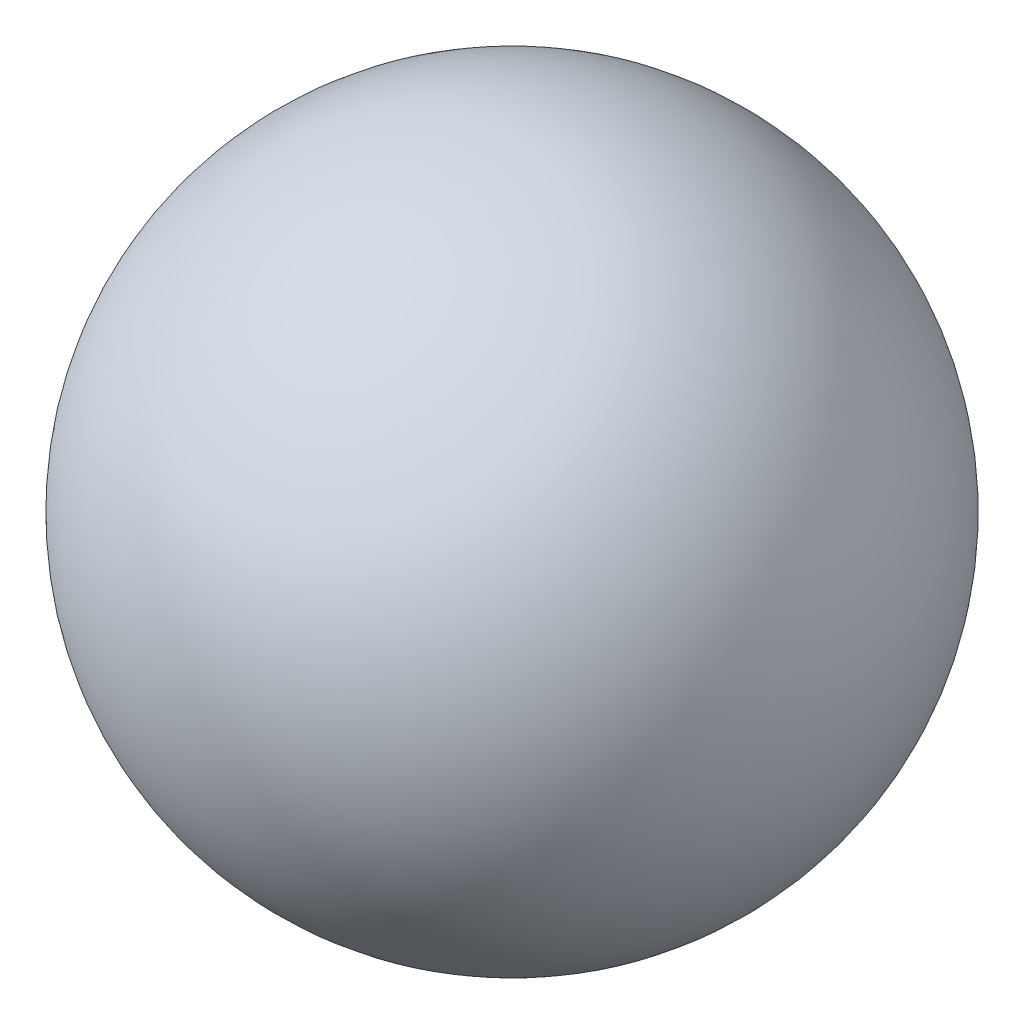
from build123d import *


with BuildPart() as part:
    # Sketch1 → Revolve2 (revolve)
    with BuildSketch(Plane.XY):
        with BuildLine():
            Line((0, 6.35), (0, -6.35))
            ThreePointArc((0, -6.35), (6.35, 0), (0, 6.35))
        make_face()
    revolve(axis=Axis((0, 6.35, 0), (0, -1, 0)))


solid = part.part
